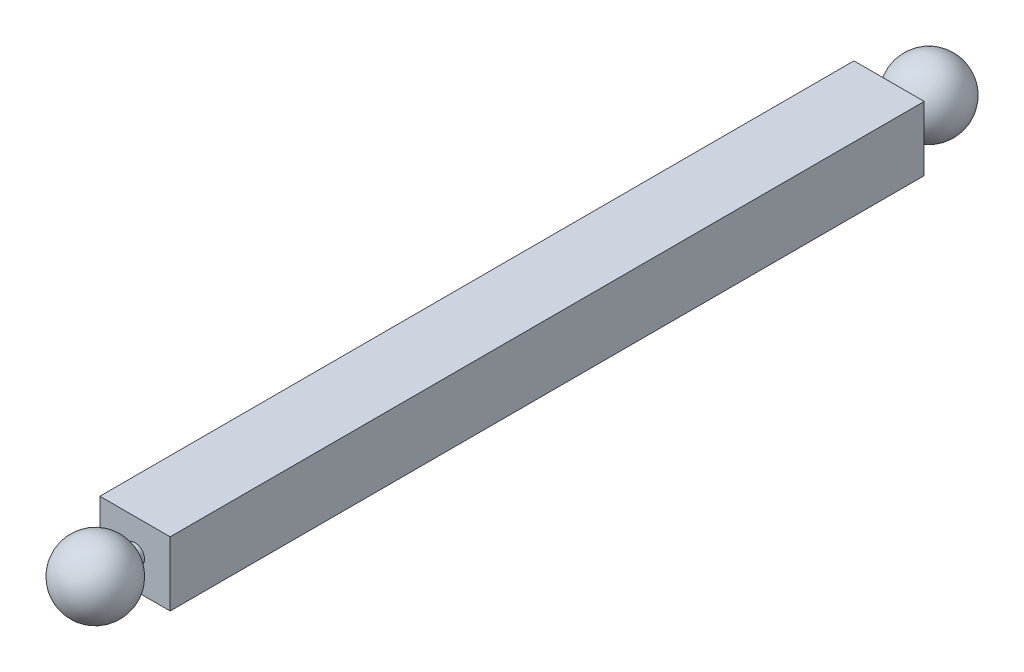
from build123d import *

# Parameters (mm, degrees)
EXTRUDE_1_DEPTH = 5
SKETCH_3_W      = 8.851756477
SKETCH_3_H      = 8.100037161
EXTRUDE_2_DEPTH = 95
SKETCH_7_R      = 0.8
EXTRUDE_3_DEPTH = 5


with BuildPart() as part:
    # 草图1 → 凸台-拉伸1 (new body)
    with BuildSketch(Plane.XY):
        with BuildLine():
            ThreePointArc((-9.310291372, -5.5207396), (-9.401635933, -5.061519481), (-9.661763234, -4.672211463))
            Line((-9.661763234, -4.672211463), (-10.510291372, -5.5207396))
            Line((-10.510291372, -5.5207396), (-9.661763234, -6.369267738))
            ThreePointArc((-9.661763234, -6.369267738), (-9.401635933, -5.979959719), (-9.310291372, -5.5207396))
        make_face()
        with BuildLine():
            Line((-10.510291372, -5.5207396), (-9.661763234, -4.672211463))
            ThreePointArc((-9.661763234, -4.672211463), (-10.510291372, -4.3207396), (-11.358819509, -4.672211463))
            Line((-11.358819509, -4.672211463), (-10.510291372, -5.5207396))
        make_face()
        with BuildLine():
            Line((-9.661763234, -6.369267738), (-10.510291372, -5.5207396))
            Line((-10.510291372, -5.5207396), (-11.358819509, -6.369267738))
            ThreePointArc((-11.358819509, -6.369267738), (-10.510291372, -6.7207396), (-9.661763234, -6.369267738))
        make_face()
        with BuildLine():
            Line((-11.358819509, -6.369267738), (-10.510291372, -5.5207396))
            Line((-10.510291372, -5.5207396), (-11.358819509, -4.672211463))
            ThreePointArc((-11.358819509, -4.672211463), (-11.710291372, -5.5207396), (-11.358819509, -6.369267738))
        make_face()
    extrude(amount=EXTRUDE_1_DEPTH)

    # 草图2 → 旋转2 (revolve)
    with BuildSketch(Plane.XY.offset(5)):
        with BuildLine():
            Line((-7.264243744, -2.550356662), (-13.756338999, -8.491122538))
            ThreePointArc((-13.756338999, -8.491122538), (-7.539908434, -8.766787228), (-7.264243744, -2.550356662))
        make_face()
    revolve(axis=Axis((-7.264243744, -2.550356662, 5), (-0.737738097, -0.675087031, 0)))

    # 草图3 → 凸台-拉伸2 (add)
    with BuildSketch(Plane(origin=(0, 0, 0), x_dir=(-1, 0, 0), z_dir=(0, 0, -1))):
        with Locations((10.510291371, -5.520739601)):
            Rectangle(SKETCH_3_W, SKETCH_3_H)
    extrude(amount=EXTRUDE_2_DEPTH)

    # 草图7 → 凸台-拉伸3 (add)
    with BuildSketch(Plane(origin=(0, 0, -95), x_dir=(-1, 0, 0), z_dir=(0, 0, -1))):
        with Locations((10.510291372, -5.5207396)):
            Circle(SKETCH_7_R)
    extrude(amount=EXTRUDE_3_DEPTH)

    # 草图5 one side → 旋转4 (revolve)
    with BuildSketch(Plane(origin=(0, 0, -100), x_dir=(-1, 0, 0), z_dir=(0, 0, -1))):
        with BuildLine():
            ThreePointArc((9.920100894, -6.060809225), (10.799987435, -6.266444764), (11.310291372, -5.5207396))
            ThreePointArc((11.310291372, -5.5207396), (11.255996535, -5.231043537), (11.100481849, -4.980669975))
            Line((11.100481849, -4.980669975), (9.920100894, -6.060809225))
        make_face()
        with BuildLine():
            ThreePointArc((7.264243744, -8.491122538), (13.48067431, -8.766787228), (13.756338999, -2.550356662))
            Line((13.756338999, -2.550356662), (7.264243744, -8.491122538))
        make_face()
    revolve(axis=Axis((-13.756338999, -2.550356662, -100), (0.737738097, -0.675087031, 0)))


solid = part.part
